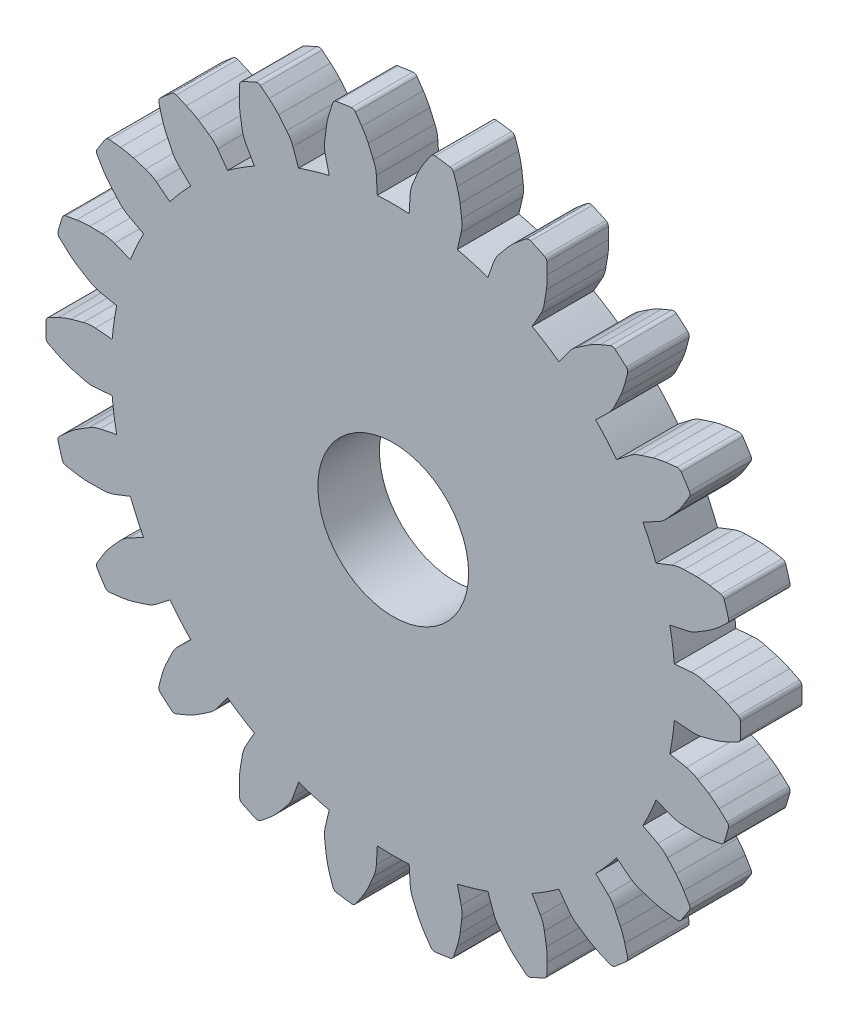
from build123d import *

# Parameters (mm, degrees)
MODEL_R             = 2.45
BOSS_EXTRUDE1_DEPTH = 2


with BuildPart() as part:
    # Model → Boss-Extrude1 (new body)
    with BuildSketch(Plane.XY):
        with BuildLine():
            Line((21.478333362, 13.198284941), (22.028135641, 13.245853358))
            ThreePointArc((22.028135641, 13.245853358), (22.228119765, 13.244009182), (22.42411707, 13.204233472))
            ThreePointArc((22.42411707, 13.204233472), (22.624155942, 13.149938636), (22.824185983, 13.095611275))
            ThreePointArc((22.824185983, 13.095611275), (23.027599002, 13.024911438), (23.224984293, 12.938804701))
            ThreePointArc((23.224984293, 12.938804701), (23.385798837, 12.860200078), (23.545769407, 12.779891792))
            ThreePointArc((23.545769407, 12.779891792), (23.60389912, 12.726789532), (23.626507212, 12.651372109))
            ThreePointArc((23.626507212, 12.651372109), (23.628480361, 12.529526062), (23.629138103, 12.407665815))
            ThreePointArc((23.629138103, 12.407665815), (23.628480361, 12.285805568), (23.626507212, 12.163959521))
            ThreePointArc((23.626507212, 12.163959521), (23.60389912, 12.088542098), (23.545769407, 12.035439838))
            ThreePointArc((23.545769407, 12.035439838), (23.385798837, 11.955131551), (23.224984293, 11.876526928))
            ThreePointArc((23.224984293, 11.876526928), (23.027599002, 11.790420191), (22.824185983, 11.719720355))
            ThreePointArc((22.824185983, 11.719720355), (22.624155942, 11.665392994), (22.42411707, 11.611098158))
            ThreePointArc((22.42411707, 11.611098158), (22.228119765, 11.571322448), (22.028135641, 11.569478272))
            Line((22.028135641, 11.569478272), (21.478333362, 11.617046689))
            ThreePointArc((21.478333362, 11.617046689), (21.452357589, 11.359266342), (21.419111439, 11.102322493))
            ThreePointArc((21.419111439, 11.102322493), (21.378621439, 10.846420152), (21.330919894, 10.591763499))
            Line((21.330919894, 10.591763499), (21.871852889, 10.482507859))
            ThreePointArc((21.871852889, 10.482507859), (22.063216687, 10.424396347), (22.240068612, 10.331013011))
            ThreePointArc((22.240068612, 10.331013011), (22.416707881, 10.222560035), (22.593329513, 10.114078338))
            ThreePointArc((22.593329513, 10.114078338), (22.76858443, 9.988934272), (22.933715159, 9.8507056))
            ThreePointArc((22.933715159, 9.8507056), (23.065870102, 9.729978324), (23.196735281, 9.60785417))
            ThreePointArc((23.196735281, 9.60785417), (23.237549697, 9.540525892), (23.237994459, 9.461793969))
            ThreePointArc((23.237994459, 9.461793969), (23.205559683, 9.344327643), (23.171858783, 9.227218284))
            ThreePointArc((23.171858783, 9.227218284), (23.136895685, 9.110479541), (23.100674464, 8.994125016))
            ThreePointArc((23.100674464, 8.994125016), (23.057734615, 8.928131963), (22.986998928, 8.893557751))
            ThreePointArc((22.986998928, 8.893557751), (22.810882832, 8.861571432), (22.634436926, 8.831457541))
            ThreePointArc((22.634436926, 8.831457541), (22.420788055, 8.804448594), (22.205696247, 8.793920669))
            ThreePointArc((22.205696247, 8.793920669), (21.998463041, 8.798148922), (21.791230526, 8.802410871))
            ThreePointArc((21.791230526, 8.802410871), (21.591966376, 8.819465179), (21.39956345, 8.874037744))
            Line((21.39956345, 8.874037744), (20.885433599, 9.074576507))
            ThreePointArc((20.885433599, 9.074576507), (20.787884911, 8.834556296), (20.683596016, 8.597387001))
            ThreePointArc((20.683596016, 8.597387001), (20.572650124, 8.363257855), (20.455135757, 8.132355664))
            Line((20.455135757, 8.132355664), (20.943376294, 7.875127209))
            ThreePointArc((20.943376294, 7.875127209), (21.110616609, 7.765456209), (21.253995662, 7.62603061))
            ThreePointArc((21.253995662, 7.62603061), (21.392925065, 7.472205708), (21.531829455, 7.318358218))
            ThreePointArc((21.531829455, 7.318358218), (21.664728159, 7.14890835), (21.784226415, 6.969756209))
            ThreePointArc((21.784226415, 6.969756209), (21.87701535, 6.816686886), (21.96817322, 6.662640636))
            ThreePointArc((21.96817322, 6.662640636), (21.988365797, 6.586540877), (21.966611197, 6.510872846))
            ThreePointArc((21.966611197, 6.510872846), (21.902396169, 6.407302663), (21.837066874, 6.304431698))
            ThreePointArc((21.837066874, 6.304431698), (21.770630922, 6.202271937), (21.703096057, 6.100835284))
            ThreePointArc((21.703096057, 6.100835284), (21.643303183, 6.049612968), (21.565692107, 6.0363678))
            ThreePointArc((21.565692107, 6.0363678), (21.387698362, 6.05529479), (21.209915692, 6.076111279))
            ThreePointArc((21.209915692, 6.076111279), (20.997311802, 6.110388228), (20.787966664, 6.160885122))
            ThreePointArc((20.787966664, 6.160885122), (20.590319096, 6.223326442), (20.392681684, 6.285799899))
            ThreePointArc((20.392681684, 6.285799899), (20.206293886, 6.358302586), (20.037059498, 6.464870746))
            Line((20.037059498, 6.464870746), (19.600253816, 6.802133399))
            ThreePointArc((19.600253816, 6.802133399), (19.439035028, 6.599318334), (19.272152254, 6.401137639))
            ThreePointArc((19.272152254, 6.401137639), (19.099738648, 6.207749437), (18.921931774, 6.019308031))
            Line((18.921931774, 6.019308031), (19.317925508, 5.634945881))
            ThreePointArc((19.317925508, 5.634945881), (19.447493523, 5.482600286), (19.545783987, 5.308427855))
            ThreePointArc((19.545783987, 5.308427855), (19.635748291, 5.121693007), (19.72568223, 4.934943533))
            ThreePointArc((19.72568223, 4.934943533), (19.805458058, 4.734915684), (19.869642804, 4.529353913))
            ThreePointArc((19.869642804, 4.529353913), (19.915548524, 4.356343309), (19.959614015, 4.182854875))
            ThreePointArc((19.959614015, 4.182854875), (19.957548872, 4.104148785), (19.915357338, 4.03767482))
            ThreePointArc((19.915357338, 4.03767482), (19.824564378, 3.956391421), (19.732899277, 3.876092842))
            ThreePointArc((19.732899277, 3.876092842), (19.640372718, 3.79678844), (19.546995482, 3.718487455))
            ThreePointArc((19.546995482, 3.718487455), (19.475193645, 3.686185601), (19.396994768, 3.695342523))
            ThreePointArc((19.396994768, 3.695342523), (19.23154337, 3.763649469), (19.06682683, 3.833709911))
            ThreePointArc((19.06682683, 3.833709911), (18.872491823, 3.926495839), (18.685853253, 4.033926596))
            ThreePointArc((18.685853253, 4.033926596), (18.513803553, 4.149522358), (18.341772652, 4.265146094))
            ThreePointArc((18.341772652, 4.265146094), (18.183361237, 4.387223424), (18.051005751, 4.537153662))
            Line((18.051005751, 4.537153662), (17.726911638, 4.983817189))
            ThreePointArc((17.726911638, 4.983817189), (17.515083737, 4.834638141), (17.299126934, 4.691501467))
            ThreePointArc((17.299126934, 4.691501467), (17.079213538, 4.554521372), (16.855519012, 4.423807152))
            Line((16.855519012, 4.423807152), (17.127184887, 3.943450043))
            ThreePointArc((17.127184887, 3.943450043), (17.208583773, 3.760771987), (17.253822738, 3.56596314))
            ThreePointArc((17.253822738, 3.56596314), (17.287533569, 3.361446491), (17.321211144, 3.156924365))
            ThreePointArc((17.321211144, 3.156924365), (17.341401134, 2.942523601), (17.345072504, 2.727205593))
            ThreePointArc((17.345072504, 2.727205593), (17.340375999, 2.548269999), (17.333779188, 2.369394382))
            ThreePointArc((17.333779188, 2.369394382), (17.30962363, 2.294458259), (17.250413269, 2.242563686))
            ThreePointArc((17.250413269, 2.242563686), (17.140397883, 2.190152169), (17.029823139, 2.13893129))
            ThreePointArc((17.029823139, 2.13893129), (16.918701923, 2.088907017), (16.807047185, 2.040085179))
            ThreePointArc((16.807047185, 2.040085179), (16.729053343, 2.029320693), (16.656601873, 2.060137864))
            ThreePointArc((16.656601873, 2.060137864), (16.517096709, 2.172290945), (16.378790653, 2.285919459))
            ThreePointArc((16.378790653, 2.285919459), (16.218468397, 2.429697403), (16.069656742, 2.58535862))
            ThreePointArc((16.069656742, 2.58535862), (15.937143354, 2.744743944), (15.804655884, 2.904150813))
            ThreePointArc((15.804655884, 2.904150813), (15.687054402, 3.065912806), (15.602300473, 3.247058665))
            Line((15.602300473, 3.247058665), (15.417174106, 3.766937044))
            ThreePointArc((15.417174106, 3.766937044), (15.171898129, 3.683479611), (14.924362833, 3.60698304))
            ThreePointArc((14.924362833, 3.60698304), (14.674765722, 3.537508366), (14.423305945, 3.475111021))
            Line((14.423305945, 3.475111021), (14.548635206, 2.937674628))
            ThreePointArc((14.548635206, 2.937674628), (14.57527051, 2.7394636), (14.563792984, 2.539800591))
            ThreePointArc((14.563792984, 2.539800591), (14.538519291, 2.334070866), (14.513212147, 2.128345252))
            ThreePointArc((14.513212147, 2.128345252), (14.472180624, 1.916941049), (14.415041185, 1.709310589))
            ThreePointArc((14.415041185, 1.709310589), (14.36012294, 1.538946302), (14.303398261, 1.369174941))
            ThreePointArc((14.303398261, 1.369174941), (14.259109227, 1.304079664), (14.187676911, 1.270968672))
            ThreePointArc((14.187676911, 1.270968672), (14.06735189, 1.251675106), (13.946825611, 1.233681538))
            ThreePointArc((13.946825611, 1.233681538), (13.826112119, 1.216990063), (13.705225481, 1.201602629))
            ThreePointArc((13.705225481, 1.201602629), (13.627358231, 1.213247584), (13.566523755, 1.263228381))
            ThreePointArc((13.566523755, 1.263228381), (13.464266705, 1.410141621), (13.363575868, 1.5581327))
            ThreePointArc((13.363575868, 1.5581327), (13.250254718, 1.741254626), (13.151325813, 1.932535559))
            ThreePointArc((13.151325813, 1.932535559), (13.069084183, 2.122797993), (12.986873491, 2.313073797))
            ThreePointArc((12.986873491, 2.313073797), (12.919609315, 2.501415458), (12.889323202, 2.699101579))
            Line((12.889323202, 2.699101579), (12.858162419, 3.250077355))
            ThreePointArc((12.858162419, 3.250077355), (12.599309166, 3.239102763), (12.340249214, 3.235443593))
            ThreePointArc((12.340249214, 3.235443593), (12.081189262, 3.239102763), (11.822336009, 3.250077355))
            Line((11.822336009, 3.250077355), (11.791175226, 2.699101579))
            ThreePointArc((11.791175226, 2.699101579), (11.760889113, 2.501415458), (11.693624938, 2.313073797))
            ThreePointArc((11.693624938, 2.313073797), (11.611414246, 2.122797993), (11.529172615, 1.932535559))
            ThreePointArc((11.529172615, 1.932535559), (11.430243711, 1.741254626), (11.31692256, 1.5581327))
            ThreePointArc((11.31692256, 1.5581327), (11.216231723, 1.410141621), (11.113974673, 1.263228381))
            ThreePointArc((11.113974673, 1.263228381), (11.053140197, 1.213247584), (10.975272948, 1.201602629))
            ThreePointArc((10.975272948, 1.201602629), (10.85438631, 1.216990063), (10.733672818, 1.233681538))
            ThreePointArc((10.733672818, 1.233681538), (10.613146539, 1.251675106), (10.492821517, 1.270968672))
            ThreePointArc((10.492821517, 1.270968672), (10.421389202, 1.304079664), (10.377100167, 1.369174941))
            ThreePointArc((10.377100167, 1.369174941), (10.320375489, 1.538946302), (10.265457243, 1.709310589))
            ThreePointArc((10.265457243, 1.709310589), (10.208317804, 1.916941049), (10.167286282, 2.128345252))
            ThreePointArc((10.167286282, 2.128345252), (10.141979137, 2.334070866), (10.116705444, 2.539800591))
            ThreePointArc((10.116705444, 2.539800591), (10.105227919, 2.7394636), (10.131863222, 2.937674628))
            Line((10.131863222, 2.937674628), (10.257192484, 3.475111021))
            ThreePointArc((10.257192484, 3.475111021), (10.005732707, 3.537508366), (9.756135596, 3.60698304))
            ThreePointArc((9.756135596, 3.60698304), (9.508600299, 3.683479611), (9.263324322, 3.766937044))
            Line((9.263324322, 3.766937044), (9.078197955, 3.247058665))
            ThreePointArc((9.078197955, 3.247058665), (8.993444026, 3.065912806), (8.875842545, 2.904150813))
            ThreePointArc((8.875842545, 2.904150813), (8.743355074, 2.744743944), (8.610841686, 2.58535862))
            ThreePointArc((8.610841686, 2.58535862), (8.462030031, 2.429697403), (8.301707775, 2.285919459))
            ThreePointArc((8.301707775, 2.285919459), (8.163401719, 2.172290945), (8.023896556, 2.060137864))
            ThreePointArc((8.023896556, 2.060137864), (7.951445086, 2.029320693), (7.873451244, 2.040085179))
            ThreePointArc((7.873451244, 2.040085179), (7.761796505, 2.088907017), (7.65067529, 2.13893129))
            ThreePointArc((7.65067529, 2.13893129), (7.540100546, 2.190152169), (7.430085159, 2.242563686))
            ThreePointArc((7.430085159, 2.242563686), (7.370874799, 2.294458259), (7.34671924, 2.369394382))
            ThreePointArc((7.34671924, 2.369394382), (7.340122429, 2.548269999), (7.335425925, 2.727205593))
            ThreePointArc((7.335425925, 2.727205593), (7.339097295, 2.942523601), (7.359287284, 3.156924365))
            ThreePointArc((7.359287284, 3.156924365), (7.392964859, 3.361446491), (7.42667569, 3.56596314))
            ThreePointArc((7.42667569, 3.56596314), (7.471914655, 3.760771987), (7.553313541, 3.943450043))
            Line((7.553313541, 3.943450043), (7.824979416, 4.423807152))
            ThreePointArc((7.824979416, 4.423807152), (7.601284891, 4.554521372), (7.381371494, 4.691501467))
            ThreePointArc((7.381371494, 4.691501467), (7.165414691, 4.834638141), (6.95358679, 4.983817189))
            Line((6.95358679, 4.983817189), (6.629492677, 4.537153662))
            ThreePointArc((6.629492677, 4.537153662), (6.497137192, 4.387223424), (6.338725777, 4.265146094))
            ThreePointArc((6.338725777, 4.265146094), (6.166694875, 4.149522358), (5.994645175, 4.033926596))
            ThreePointArc((5.994645175, 4.033926596), (5.808006605, 3.926495839), (5.613671599, 3.833709911))
            ThreePointArc((5.613671599, 3.833709911), (5.448955058, 3.763649469), (5.28350366, 3.695342523))
            ThreePointArc((5.28350366, 3.695342523), (5.205304783, 3.686185601), (5.133502946, 3.718487455))
            ThreePointArc((5.133502946, 3.718487455), (5.04012571, 3.79678844), (4.947599151, 3.876092842))
            ThreePointArc((4.947599151, 3.876092842), (4.855934051, 3.956391421), (4.765141091, 4.03767482))
            ThreePointArc((4.765141091, 4.03767482), (4.722949557, 4.104148785), (4.720884413, 4.182854875))
            ThreePointArc((4.720884413, 4.182854875), (4.764949904, 4.356343309), (4.810855624, 4.529353913))
            ThreePointArc((4.810855624, 4.529353913), (4.875040371, 4.734915684), (4.954816199, 4.934943533))
            ThreePointArc((4.954816199, 4.934943533), (5.044750138, 5.121693007), (5.134714441, 5.308427855))
            ThreePointArc((5.134714441, 5.308427855), (5.233004905, 5.482600286), (5.36257292, 5.634945881))
            Line((5.36257292, 5.634945881), (5.758566655, 6.019308031))
            ThreePointArc((5.758566655, 6.019308031), (5.580759781, 6.207749437), (5.408346174, 6.401137639))
            ThreePointArc((5.408346174, 6.401137639), (5.2414634, 6.599318334), (5.080244612, 6.802133399))
            Line((5.080244612, 6.802133399), (4.64343893, 6.464870746))
            ThreePointArc((4.64343893, 6.464870746), (4.474204543, 6.358302586), (4.287816745, 6.285799899))
            ThreePointArc((4.287816745, 6.285799899), (4.090179333, 6.223326442), (3.892531765, 6.160885122))
            ThreePointArc((3.892531765, 6.160885122), (3.683186627, 6.110388228), (3.470582737, 6.076111279))
            ThreePointArc((3.470582737, 6.076111279), (3.292800066, 6.05529479), (3.114806321, 6.0363678))
            ThreePointArc((3.114806321, 6.0363678), (3.037195246, 6.049612968), (2.977402371, 6.100835284))
            ThreePointArc((2.977402371, 6.100835284), (2.909867506, 6.202271937), (2.843431555, 6.304431698))
            ThreePointArc((2.843431555, 6.304431698), (2.778102259, 6.407302663), (2.713887231, 6.510872846))
            ThreePointArc((2.713887231, 6.510872846), (2.692132631, 6.586540877), (2.712325209, 6.662640636))
            ThreePointArc((2.712325209, 6.662640636), (2.803483078, 6.816686886), (2.896272013, 6.969756209))
            ThreePointArc((2.896272013, 6.969756209), (3.01577027, 7.14890835), (3.148668974, 7.318358218))
            ThreePointArc((3.148668974, 7.318358218), (3.287573363, 7.472205708), (3.426502766, 7.62603061))
            ThreePointArc((3.426502766, 7.62603061), (3.56988182, 7.765456209), (3.737122134, 7.875127209))
            Line((3.737122134, 7.875127209), (4.225362671, 8.132355664))
            ThreePointArc((4.225362671, 8.132355664), (4.107848304, 8.363257855), (3.996902412, 8.597387001))
            ThreePointArc((3.996902412, 8.597387001), (3.892613518, 8.834556296), (3.79506483, 9.074576507))
            Line((3.79506483, 9.074576507), (3.280934978, 8.874037744))
            ThreePointArc((3.280934978, 8.874037744), (3.088532052, 8.819465179), (2.889267902, 8.802410871))
            ThreePointArc((2.889267902, 8.802410871), (2.682035387, 8.798148922), (2.474802182, 8.793920669))
            ThreePointArc((2.474802182, 8.793920669), (2.259710373, 8.804448594), (2.046061503, 8.831457541))
            ThreePointArc((2.046061503, 8.831457541), (1.869615597, 8.861571432), (1.6934995, 8.893557751))
            ThreePointArc((1.6934995, 8.893557751), (1.622763813, 8.928131963), (1.579823964, 8.994125016))
            ThreePointArc((1.579823964, 8.994125016), (1.543602743, 9.110479541), (1.508639645, 9.227218284))
            ThreePointArc((1.508639645, 9.227218284), (1.474938745, 9.344327643), (1.44250397, 9.461793969))
            ThreePointArc((1.44250397, 9.461793969), (1.442948732, 9.540525892), (1.483763148, 9.60785417))
            ThreePointArc((1.483763148, 9.60785417), (1.614628326, 9.729978324), (1.74678327, 9.8507056))
            ThreePointArc((1.74678327, 9.8507056), (1.911913998, 9.988934272), (2.087168915, 10.114078338))
            ThreePointArc((2.087168915, 10.114078338), (2.263790547, 10.222560035), (2.440429817, 10.331013011))
            ThreePointArc((2.440429817, 10.331013011), (2.617281742, 10.424396347), (2.808645539, 10.482507859))
            Line((2.808645539, 10.482507859), (3.349578534, 10.591763499))
            ThreePointArc((3.349578534, 10.591763499), (3.301876989, 10.846420152), (3.261386989, 11.102322493))
            ThreePointArc((3.261386989, 11.102322493), (3.228140839, 11.359266342), (3.202165066, 11.617046689))
            Line((3.202165066, 11.617046689), (2.652362788, 11.569478272))
            ThreePointArc((2.652362788, 11.569478272), (2.452378664, 11.571322448), (2.256381358, 11.611098158))
            ThreePointArc((2.256381358, 11.611098158), (2.056342486, 11.665392994), (1.856312445, 11.719720355))
            ThreePointArc((1.856312445, 11.719720355), (1.652899426, 11.790420191), (1.455514135, 11.876526928))
            ThreePointArc((1.455514135, 11.876526928), (1.294699592, 11.955131551), (1.134729022, 12.035439838))
            ThreePointArc((1.134729022, 12.035439838), (1.076599308, 12.088542098), (1.053991217, 12.163959521))
            ThreePointArc((1.053991217, 12.163959521), (1.052018067, 12.285805568), (1.051360325, 12.407665815))
            ThreePointArc((1.051360325, 12.407665815), (1.052018067, 12.529526062), (1.053991217, 12.651372109))
            ThreePointArc((1.053991217, 12.651372109), (1.076599308, 12.726789532), (1.134729022, 12.779891792))
            ThreePointArc((1.134729022, 12.779891792), (1.294699592, 12.860200078), (1.455514135, 12.938804701))
            ThreePointArc((1.455514135, 12.938804701), (1.652899426, 13.024911438), (1.856312445, 13.095611275))
            ThreePointArc((1.856312445, 13.095611275), (2.056342486, 13.149938636), (2.256381358, 13.204233472))
            ThreePointArc((2.256381358, 13.204233472), (2.452378664, 13.244009182), (2.652362788, 13.245853358))
            Line((2.652362788, 13.245853358), (3.202165066, 13.198284941))
            ThreePointArc((3.202165066, 13.198284941), (3.228140839, 13.456065288), (3.261386989, 13.713009137))
            ThreePointArc((3.261386989, 13.713009137), (3.301876989, 13.968911478), (3.349578534, 14.223568131))
            Line((3.349578534, 14.223568131), (2.808645539, 14.332823771))
            ThreePointArc((2.808645539, 14.332823771), (2.617281742, 14.390935283), (2.440429817, 14.484318619))
            ThreePointArc((2.440429817, 14.484318619), (2.263790547, 14.592771595), (2.087168915, 14.701253292))
            ThreePointArc((2.087168915, 14.701253292), (1.911913998, 14.826397358), (1.74678327, 14.96462603))
            ThreePointArc((1.74678327, 14.96462603), (1.614628326, 15.085353306), (1.483763148, 15.20747746))
            ThreePointArc((1.483763148, 15.20747746), (1.442948732, 15.274805738), (1.44250397, 15.353537661))
            ThreePointArc((1.44250397, 15.353537661), (1.474938745, 15.471003987), (1.508639645, 15.588113346))
            ThreePointArc((1.508639645, 15.588113346), (1.543602743, 15.704852089), (1.579823964, 15.821206614))
            ThreePointArc((1.579823964, 15.821206614), (1.622763813, 15.887199667), (1.6934995, 15.921773879))
            ThreePointArc((1.6934995, 15.921773879), (1.869615597, 15.953760198), (2.046061503, 15.983874089))
            ThreePointArc((2.046061503, 15.983874089), (2.259710373, 16.010883035), (2.474802182, 16.021410961))
            ThreePointArc((2.474802182, 16.021410961), (2.682035387, 16.017182708), (2.889267902, 16.012920759))
            ThreePointArc((2.889267902, 16.012920759), (3.088532052, 15.995866451), (3.280934978, 15.941293886))
            Line((3.280934978, 15.941293886), (3.79506483, 15.740755122))
            ThreePointArc((3.79506483, 15.740755122), (3.892613518, 15.980775333), (3.996902412, 16.217944629))
            ThreePointArc((3.996902412, 16.217944629), (4.107848304, 16.452073775), (4.225362671, 16.682975966))
            Line((4.225362671, 16.682975966), (3.737122134, 16.940204421))
            ThreePointArc((3.737122134, 16.940204421), (3.56988182, 17.04987542), (3.426502766, 17.18930102))
            ThreePointArc((3.426502766, 17.18930102), (3.287573363, 17.343125922), (3.148668974, 17.496973412))
            ThreePointArc((3.148668974, 17.496973412), (3.01577027, 17.666423279), (2.896272013, 17.845575421))
            ThreePointArc((2.896272013, 17.845575421), (2.803483078, 17.998644744), (2.712325209, 18.152690994))
            ThreePointArc((2.712325209, 18.152690994), (2.692132631, 18.228790753), (2.713887231, 18.304458784))
            ThreePointArc((2.713887231, 18.304458784), (2.778102259, 18.408028966), (2.843431555, 18.510899932))
            ThreePointArc((2.843431555, 18.510899932), (2.909867506, 18.613059693), (2.977402371, 18.714496345))
            ThreePointArc((2.977402371, 18.714496345), (3.037195246, 18.765718662), (3.114806321, 18.77896383))
            ThreePointArc((3.114806321, 18.77896383), (3.292800066, 18.76003684), (3.470582737, 18.739220351))
            ThreePointArc((3.470582737, 18.739220351), (3.683186627, 18.704943402), (3.892531765, 18.654446508))
            ThreePointArc((3.892531765, 18.654446508), (4.090179333, 18.592005188), (4.287816745, 18.529531731))
            ThreePointArc((4.287816745, 18.529531731), (4.474204543, 18.457029044), (4.64343893, 18.350460883))
            Line((4.64343893, 18.350460883), (5.080244612, 18.013198231))
            ThreePointArc((5.080244612, 18.013198231), (5.2414634, 18.216013296), (5.408346174, 18.414193991))
            ThreePointArc((5.408346174, 18.414193991), (5.580759781, 18.607582193), (5.758566655, 18.796023599))
            Line((5.758566655, 18.796023599), (5.36257292, 19.180385749))
            ThreePointArc((5.36257292, 19.180385749), (5.233004905, 19.332731344), (5.134714441, 19.506903775))
            ThreePointArc((5.134714441, 19.506903775), (5.044750138, 19.693638623), (4.954816199, 19.880388097))
            ThreePointArc((4.954816199, 19.880388097), (4.875040371, 20.080415946), (4.810855624, 20.285977717))
            ThreePointArc((4.810855624, 20.285977717), (4.764949904, 20.458988321), (4.720884413, 20.632476755))
            ThreePointArc((4.720884413, 20.632476755), (4.722949557, 20.711182845), (4.765141091, 20.77765681))
            ThreePointArc((4.765141091, 20.77765681), (4.855934051, 20.858940209), (4.947599151, 20.939238788))
            ThreePointArc((4.947599151, 20.939238788), (5.04012571, 21.01854319), (5.133502946, 21.096844175))
            ThreePointArc((5.133502946, 21.096844175), (5.205304783, 21.129146029), (5.28350366, 21.119989107))
            ThreePointArc((5.28350366, 21.119989107), (5.448955058, 21.051682161), (5.613671599, 20.981621719))
            ThreePointArc((5.613671599, 20.981621719), (5.808006605, 20.888835791), (5.994645175, 20.781405034))
            ThreePointArc((5.994645175, 20.781405034), (6.166694875, 20.665809272), (6.338725777, 20.550185536))
            ThreePointArc((6.338725777, 20.550185536), (6.497137192, 20.428108206), (6.629492677, 20.278177968))
            Line((6.629492677, 20.278177968), (6.95358679, 19.831514441))
            ThreePointArc((6.95358679, 19.831514441), (7.165414691, 19.980693489), (7.381371494, 20.123830163))
            ThreePointArc((7.381371494, 20.123830163), (7.601284891, 20.260810257), (7.824979416, 20.391524478))
            Line((7.824979416, 20.391524478), (7.553313541, 20.871881587))
            ThreePointArc((7.553313541, 20.871881587), (7.471914655, 21.054559643), (7.42667569, 21.24936849))
            ThreePointArc((7.42667569, 21.24936849), (7.392964859, 21.453885138), (7.359287284, 21.658407265))
            ThreePointArc((7.359287284, 21.658407265), (7.339097295, 21.872808029), (7.335425925, 22.088126036))
            ThreePointArc((7.335425925, 22.088126036), (7.340122429, 22.267061631), (7.34671924, 22.445937248))
            ThreePointArc((7.34671924, 22.445937248), (7.370874799, 22.520873371), (7.430085159, 22.572767944))
            ThreePointArc((7.430085159, 22.572767944), (7.540100546, 22.625179461), (7.65067529, 22.67640034))
            ThreePointArc((7.65067529, 22.67640034), (7.761796505, 22.726424613), (7.873451244, 22.775246451))
            ThreePointArc((7.873451244, 22.775246451), (7.951445086, 22.786010937), (8.023896556, 22.755193766))
            ThreePointArc((8.023896556, 22.755193766), (8.163401719, 22.643040685), (8.301707775, 22.529412171))
            ThreePointArc((8.301707775, 22.529412171), (8.462030031, 22.385634227), (8.610841686, 22.229973009))
            ThreePointArc((8.610841686, 22.229973009), (8.743355074, 22.070587686), (8.875842545, 21.911180817))
            ThreePointArc((8.875842545, 21.911180817), (8.993444026, 21.749418824), (9.078197955, 21.568272965))
            Line((9.078197955, 21.568272965), (9.263324322, 21.048394586))
            ThreePointArc((9.263324322, 21.048394586), (9.508600299, 21.131852019), (9.756135596, 21.20834859))
            ThreePointArc((9.756135596, 21.20834859), (10.005732707, 21.277823264), (10.257192484, 21.340220609))
            Line((10.257192484, 21.340220609), (10.131863222, 21.877657002))
            ThreePointArc((10.131863222, 21.877657002), (10.105227919, 22.07586803), (10.116705444, 22.275531039))
            ThreePointArc((10.116705444, 22.275531039), (10.141979137, 22.481260764), (10.167286282, 22.686986378))
            ThreePointArc((10.167286282, 22.686986378), (10.208317804, 22.898390581), (10.265457243, 23.106021041))
            ThreePointArc((10.265457243, 23.106021041), (10.320375489, 23.276385328), (10.377100167, 23.446156689))
            ThreePointArc((10.377100167, 23.446156689), (10.421389202, 23.511251965), (10.492821517, 23.544362958))
            ThreePointArc((10.492821517, 23.544362958), (10.613146539, 23.563656524), (10.733672818, 23.581650092))
            ThreePointArc((10.733672818, 23.581650092), (10.85438631, 23.598341566), (10.975272948, 23.613729001))
            ThreePointArc((10.975272948, 23.613729001), (11.053140197, 23.602084046), (11.113974673, 23.552103249))
            ThreePointArc((11.113974673, 23.552103249), (11.216231723, 23.405190009), (11.31692256, 23.25719893))
            ThreePointArc((11.31692256, 23.25719893), (11.430243711, 23.074077003), (11.529172615, 22.882796071))
            ThreePointArc((11.529172615, 22.882796071), (11.611414246, 22.692533637), (11.693624938, 22.502257833))
            ThreePointArc((11.693624938, 22.502257833), (11.760889113, 22.313916171), (11.791175226, 22.116230051))
            Line((11.791175226, 22.116230051), (11.822336009, 21.565254275))
            ThreePointArc((11.822336009, 21.565254275), (12.081189262, 21.576228867), (12.340249214, 21.579888037))
            ThreePointArc((12.340249214, 21.579888037), (12.599309166, 21.576228867), (12.858162419, 21.565254275))
            Line((12.858162419, 21.565254275), (12.889323202, 22.116230051))
            ThreePointArc((12.889323202, 22.116230051), (12.919609315, 22.313916171), (12.986873491, 22.502257833))
            ThreePointArc((12.986873491, 22.502257833), (13.069084183, 22.692533637), (13.151325813, 22.882796071))
            ThreePointArc((13.151325813, 22.882796071), (13.250254718, 23.074077003), (13.363575868, 23.25719893))
            ThreePointArc((13.363575868, 23.25719893), (13.464266705, 23.405190009), (13.566523755, 23.552103249))
            ThreePointArc((13.566523755, 23.552103249), (13.627358231, 23.602084046), (13.705225481, 23.613729001))
            ThreePointArc((13.705225481, 23.613729001), (13.826112119, 23.598341566), (13.946825611, 23.581650092))
            ThreePointArc((13.946825611, 23.581650092), (14.06735189, 23.563656524), (14.187676911, 23.544362958))
            ThreePointArc((14.187676911, 23.544362958), (14.259109227, 23.511251965), (14.303398261, 23.446156689))
            ThreePointArc((14.303398261, 23.446156689), (14.36012294, 23.276385328), (14.415041185, 23.106021041))
            ThreePointArc((14.415041185, 23.106021041), (14.472180624, 22.898390581), (14.513212147, 22.686986378))
            ThreePointArc((14.513212147, 22.686986378), (14.538519291, 22.481260764), (14.563792984, 22.275531039))
            ThreePointArc((14.563792984, 22.275531039), (14.57527051, 22.07586803), (14.548635206, 21.877657002))
            Line((14.548635206, 21.877657002), (14.423305945, 21.340220609))
            ThreePointArc((14.423305945, 21.340220609), (14.674765722, 21.277823264), (14.924362833, 21.20834859))
            ThreePointArc((14.924362833, 21.20834859), (15.171898129, 21.131852019), (15.417174106, 21.048394586))
            Line((15.417174106, 21.048394586), (15.602300473, 21.568272965))
            ThreePointArc((15.602300473, 21.568272965), (15.687054402, 21.749418824), (15.804655884, 21.911180817))
            ThreePointArc((15.804655884, 21.911180817), (15.937143354, 22.070587686), (16.069656742, 22.229973009))
            ThreePointArc((16.069656742, 22.229973009), (16.218468397, 22.385634227), (16.378790653, 22.529412171))
            ThreePointArc((16.378790653, 22.529412171), (16.517096709, 22.643040685), (16.656601873, 22.755193766))
            ThreePointArc((16.656601873, 22.755193766), (16.729053343, 22.786010937), (16.807047185, 22.775246451))
            ThreePointArc((16.807047185, 22.775246451), (16.918701923, 22.726424613), (17.029823139, 22.67640034))
            ThreePointArc((17.029823139, 22.67640034), (17.140397883, 22.625179461), (17.250413269, 22.572767944))
            ThreePointArc((17.250413269, 22.572767944), (17.30962363, 22.520873371), (17.333779188, 22.445937248))
            ThreePointArc((17.333779188, 22.445937248), (17.340375999, 22.267061631), (17.345072504, 22.088126036))
            ThreePointArc((17.345072504, 22.088126036), (17.341401134, 21.872808029), (17.321211144, 21.658407265))
            ThreePointArc((17.321211144, 21.658407265), (17.287533569, 21.453885138), (17.253822738, 21.24936849))
            ThreePointArc((17.253822738, 21.24936849), (17.208583773, 21.054559643), (17.127184887, 20.871881587))
            Line((17.127184887, 20.871881587), (16.855519012, 20.391524478))
            ThreePointArc((16.855519012, 20.391524478), (17.079213538, 20.260810257), (17.299126934, 20.123830163))
            ThreePointArc((17.299126934, 20.123830163), (17.515083737, 19.980693489), (17.726911638, 19.831514441))
            Line((17.726911638, 19.831514441), (18.051005751, 20.278177968))
            ThreePointArc((18.051005751, 20.278177968), (18.183361237, 20.428108206), (18.341772652, 20.550185536))
            ThreePointArc((18.341772652, 20.550185536), (18.513803553, 20.665809272), (18.685853253, 20.781405034))
            ThreePointArc((18.685853253, 20.781405034), (18.872491823, 20.888835791), (19.06682683, 20.981621719))
            ThreePointArc((19.06682683, 20.981621719), (19.23154337, 21.051682161), (19.396994768, 21.119989107))
            ThreePointArc((19.396994768, 21.119989107), (19.475193645, 21.129146029), (19.546995482, 21.096844175))
            ThreePointArc((19.546995482, 21.096844175), (19.640372718, 21.01854319), (19.732899277, 20.939238788))
            ThreePointArc((19.732899277, 20.939238788), (19.824564378, 20.858940209), (19.915357338, 20.77765681))
            ThreePointArc((19.915357338, 20.77765681), (19.957548872, 20.711182845), (19.959614015, 20.632476755))
            ThreePointArc((19.959614015, 20.632476755), (19.915548524, 20.458988321), (19.869642804, 20.285977717))
            ThreePointArc((19.869642804, 20.285977717), (19.805458058, 20.080415946), (19.72568223, 19.880388097))
            ThreePointArc((19.72568223, 19.880388097), (19.635748291, 19.693638623), (19.545783987, 19.506903775))
            ThreePointArc((19.545783987, 19.506903775), (19.447493523, 19.332731344), (19.317925508, 19.180385749))
            Line((19.317925508, 19.180385749), (18.921931774, 18.796023599))
            ThreePointArc((18.921931774, 18.796023599), (19.099738648, 18.607582193), (19.272152254, 18.414193991))
            ThreePointArc((19.272152254, 18.414193991), (19.439035028, 18.216013296), (19.600253816, 18.013198231))
            Line((19.600253816, 18.013198231), (20.037059498, 18.350460883))
            ThreePointArc((20.037059498, 18.350460883), (20.206293886, 18.457029044), (20.392681684, 18.529531731))
            ThreePointArc((20.392681684, 18.529531731), (20.590319096, 18.592005188), (20.787966664, 18.654446508))
            ThreePointArc((20.787966664, 18.654446508), (20.997311802, 18.704943402), (21.209915692, 18.739220351))
            ThreePointArc((21.209915692, 18.739220351), (21.387698362, 18.76003684), (21.565692107, 18.77896383))
            ThreePointArc((21.565692107, 18.77896383), (21.643303183, 18.765718662), (21.703096057, 18.714496345))
            ThreePointArc((21.703096057, 18.714496345), (21.770630922, 18.613059693), (21.837066874, 18.510899932))
            ThreePointArc((21.837066874, 18.510899932), (21.902396169, 18.408028966), (21.966611197, 18.304458784))
            ThreePointArc((21.966611197, 18.304458784), (21.988365797, 18.228790753), (21.96817322, 18.152690994))
            ThreePointArc((21.96817322, 18.152690994), (21.87701535, 17.998644744), (21.784226415, 17.845575421))
            ThreePointArc((21.784226415, 17.845575421), (21.664728159, 17.666423279), (21.531829455, 17.496973412))
            ThreePointArc((21.531829455, 17.496973412), (21.392925065, 17.343125922), (21.253995662, 17.18930102))
            ThreePointArc((21.253995662, 17.18930102), (21.110616609, 17.04987542), (20.943376294, 16.940204421))
            Line((20.943376294, 16.940204421), (20.455135757, 16.682975966))
            ThreePointArc((20.455135757, 16.682975966), (20.572650124, 16.452073775), (20.683596016, 16.217944629))
            ThreePointArc((20.683596016, 16.217944629), (20.787884911, 15.980775333), (20.885433599, 15.740755122))
            Line((20.885433599, 15.740755122), (21.39956345, 15.941293886))
            ThreePointArc((21.39956345, 15.941293886), (21.591966376, 15.995866451), (21.791230526, 16.012920759))
            ThreePointArc((21.791230526, 16.012920759), (21.998463041, 16.017182708), (22.205696247, 16.021410961))
            ThreePointArc((22.205696247, 16.021410961), (22.420788055, 16.010883035), (22.634436926, 15.983874089))
            ThreePointArc((22.634436926, 15.983874089), (22.810882832, 15.953760198), (22.986998928, 15.921773879))
            ThreePointArc((22.986998928, 15.921773879), (23.057734615, 15.887199667), (23.100674464, 15.821206614))
            ThreePointArc((23.100674464, 15.821206614), (23.136895685, 15.704852089), (23.171858783, 15.588113346))
            ThreePointArc((23.171858783, 15.588113346), (23.205559683, 15.471003987), (23.237994459, 15.353537661))
            ThreePointArc((23.237994459, 15.353537661), (23.237549697, 15.274805738), (23.196735281, 15.20747746))
            ThreePointArc((23.196735281, 15.20747746), (23.065870102, 15.085353306), (22.933715159, 14.96462603))
            ThreePointArc((22.933715159, 14.96462603), (22.76858443, 14.826397358), (22.593329513, 14.701253292))
            ThreePointArc((22.593329513, 14.701253292), (22.416707881, 14.592771595), (22.240068612, 14.484318619))
            ThreePointArc((22.240068612, 14.484318619), (22.063216687, 14.390935283), (21.871852889, 14.332823771))
            Line((21.871852889, 14.332823771), (21.330919894, 14.223568131))
            ThreePointArc((21.330919894, 14.223568131), (21.378621439, 13.968911478), (21.419111439, 13.713009137))
            ThreePointArc((21.419111439, 13.713009137), (21.452357589, 13.456065288), (21.478333362, 13.198284941))
        make_face()
        with Locations((12.340249214, 12.407665815)):
            Circle(MODEL_R, mode=Mode.SUBTRACT)
    extrude(amount=BOSS_EXTRUDE1_DEPTH)


solid = part.part
